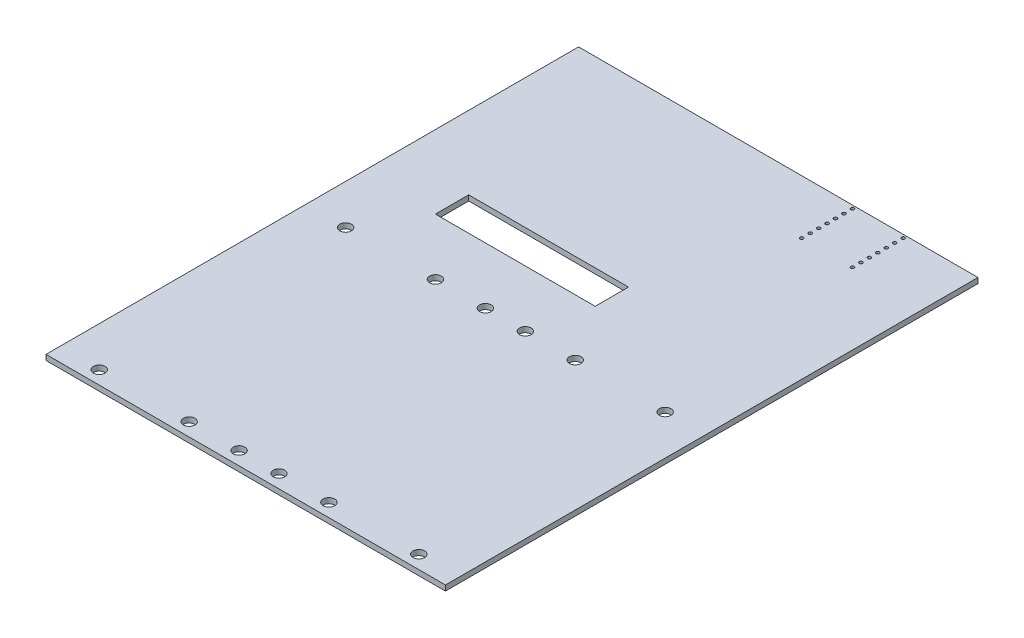
from build123d import *

# Parameters (mm, degrees)
SKETCH1_W           = 120
SKETCH1_H           = 160
SKETCH1_W_2         = 48
SKETCH1_H_2         = 10
SKETCH1_R           = 0.5
SKETCH1_R_2         = 1.75
BOSS_EXTRUDE2_DEPTH = 1.6


with BuildPart() as part:
    # Sketch1 → Boss-Extrude2 (new body)
    with BuildSketch(Plane(origin=(0, 0, 0), x_dir=(1, 0, 0), z_dir=(0, 1, 0))):
        with Locations((60, -80)):
            Rectangle(SKETCH1_W, SKETCH1_H)
        with Locations((46, -60)):
            Rectangle(SKETCH1_W_2, SKETCH1_H_2, mode=Mode.SUBTRACT)
        with Locations((98.497526801, -6.06)):
            Circle(SKETCH1_R, mode=Mode.SUBTRACT)
        with Locations((98.497526801, -3.52)):
            Circle(SKETCH1_R, mode=Mode.SUBTRACT)
        with Locations((98.497526801, -0.98)):
            Circle(SKETCH1_R, mode=Mode.SUBTRACT)
        with Locations((83.257526801, -16.22)):
            Circle(SKETCH1_R, mode=Mode.SUBTRACT)
        with Locations((83.257526801, -13.68)):
            Circle(SKETCH1_R, mode=Mode.SUBTRACT)
        with Locations((83.257526801, -11.14)):
            Circle(SKETCH1_R, mode=Mode.SUBTRACT)
        with Locations((83.257526801, -8.6)):
            Circle(SKETCH1_R, mode=Mode.SUBTRACT)
        with Locations((83.257526801, -6.06)):
            Circle(SKETCH1_R, mode=Mode.SUBTRACT)
        with Locations((83.257526801, -3.52)):
            Circle(SKETCH1_R, mode=Mode.SUBTRACT)
        with Locations((83.257526801, -0.98)):
            Circle(SKETCH1_R, mode=Mode.SUBTRACT)
        with Locations((98.497526801, -16.22)):
            Circle(SKETCH1_R, mode=Mode.SUBTRACT)
        with Locations((98.497526801, -13.68)):
            Circle(SKETCH1_R, mode=Mode.SUBTRACT)
        with Locations((98.497526801, -11.14)):
            Circle(SKETCH1_R, mode=Mode.SUBTRACT)
        with Locations((98.497526801, -8.6)):
            Circle(SKETCH1_R, mode=Mode.SUBTRACT)
        with Locations((108, -156)):
            Circle(SKETCH1_R_2, mode=Mode.SUBTRACT)
        with Locations((108, -82)):
            Circle(SKETCH1_R_2, mode=Mode.SUBTRACT)
        with Locations((81, -82)):
            Circle(SKETCH1_R_2, mode=Mode.SUBTRACT)
        with Locations((66, -82)):
            Circle(SKETCH1_R_2, mode=Mode.SUBTRACT)
        with Locations((66, -156)):
            Circle(SKETCH1_R_2, mode=Mode.SUBTRACT)
        with Locations((81, -156)):
            Circle(SKETCH1_R_2, mode=Mode.SUBTRACT)
        with Locations((54, -82)):
            Circle(SKETCH1_R_2, mode=Mode.SUBTRACT)
        with Locations((39, -82)):
            Circle(SKETCH1_R_2, mode=Mode.SUBTRACT)
        with Locations((39, -156)):
            Circle(SKETCH1_R_2, mode=Mode.SUBTRACT)
        with Locations((54, -156)):
            Circle(SKETCH1_R_2, mode=Mode.SUBTRACT)
        with Locations((12, -156)):
            Circle(SKETCH1_R_2, mode=Mode.SUBTRACT)
        with Locations((12, -82)):
            Circle(SKETCH1_R_2, mode=Mode.SUBTRACT)
    extrude(amount=BOSS_EXTRUDE2_DEPTH)


solid = part.part
